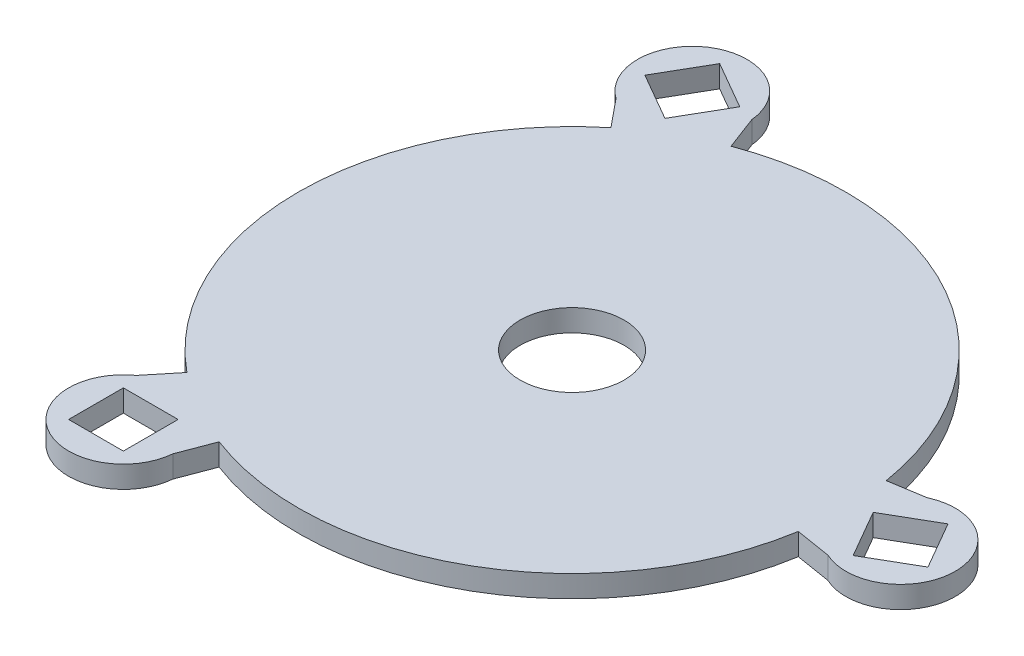
from build123d import *

# Parameters (mm, degrees)
SKETCH1_W           = 5
SKETCH1_H           = 5
BOSS_EXTRUDE1_DEPTH = 2
CUT_EXTRUDE1_REACH  = 48.785
SKETCH2_R           = 4.75
SKETCH3_R           = 1.9
BOSS_EXTRUDE2_DEPTH = 2
FILLET1_R           = 0.5


with BuildPart() as part:
    # Sketch1 → Boss-Extrude1 (new body)
    with BuildSketch(Plane(origin=(0, 0, 0), x_dir=(1, 0, 0), z_dir=(0, 1, 0))):
        with BuildLine():
            ThreePointArc((-8.860443092, -23.377180074), (12.5, -21.650635095), (24.675453359, -4.01522123))
            Line((24.675453359, -4.01522123), (27.907701299, -4.541176736))
            ThreePointArc((27.907701299, -4.541176736), (35, 0), (27.907701299, 4.541176736))
            Line((27.907701299, 4.541176736), (24.675453359, 4.01522123))
            ThreePointArc((24.675453359, 4.01522123), (12.5, 21.650635095), (-8.860443092, 23.377180074))
            Line((-8.860443092, 23.377180074), (-10.021076233, 26.439366654))
            ThreePointArc((-10.021076233, 26.439366654), (-17.5, 30.310889132), (-17.886625066, 21.898189918))
            Line((-17.886625066, 21.898189918), (-15.815010267, 19.361958844))
            ThreePointArc((-15.815010267, 19.361958844), (-25, 0), (-15.815010267, -19.361958844))
            Line((-15.815010267, -19.361958844), (-17.886625066, -21.898189918))
            ThreePointArc((-17.886625066, -21.898189918), (-17.5, -30.310889132), (-10.021076233, -26.439366654))
            Line((-10.021076233, -26.439366654), (-8.860443092, -23.377180074))
        make_face()
        with Locations((-15, -25.980762114)):
            Rectangle(SKETCH1_W, SKETCH1_H, mode=Mode.SUBTRACT)
        Polygon((26.584936491, 0.915063509), (30.915063509, 3.415063509), (33.415063509, -0.915063509), (29.084936491, -3.415063509), align=None, mode=Mode.SUBTRACT)
        Polygon((-11.584936491, 26.895825623), (-14.084936491, 22.565698604), (-18.415063509, 25.065698604), (-15.915063509, 29.395825623), align=None, mode=Mode.SUBTRACT)
    extrude(amount=BOSS_EXTRUDE1_DEPTH)

    # Sketch2 → Cut-Extrude1 (cut, up to next)
    with BuildSketch(Plane(origin=(0, 0, 0), x_dir=(-1, 0, 0), z_dir=(0, -1, 0)), mode=Mode.PRIVATE) as cut_extrude1_sk1:
        Circle(SKETCH2_R)
    cut_extrude1_tool1 = extrude(cut_extrude1_sk1.sketch, amount=-CUT_EXTRUDE1_REACH, mode=Mode.PRIVATE) & part.part
    add(cut_extrude1_tool1.solids().sort_by_distance((0, 0, 0))[0], mode=Mode.SUBTRACT)

    # Sketch3 → Boss-Extrude2 (add)
    with BuildSketch(Plane(origin=(0, 0, 0), x_dir=(-1, 0, 0), z_dir=(0, -1, 0))):
        with Locations((17.5, 8)):
            Circle(SKETCH3_R)
        with Locations((-17.5, 8)):
            Circle(SKETCH3_R)
    extrude(amount=BOSS_EXTRUDE2_DEPTH)

    # Fillet1
    fillet1_edges = [part.edges().sort_by_distance(p)[0] for p in [
        (19.4, -2, -8),
        (-15.6, -2, -8),
    ]]
    fillet(fillet1_edges, radius=FILLET1_R)


solid = part.part
